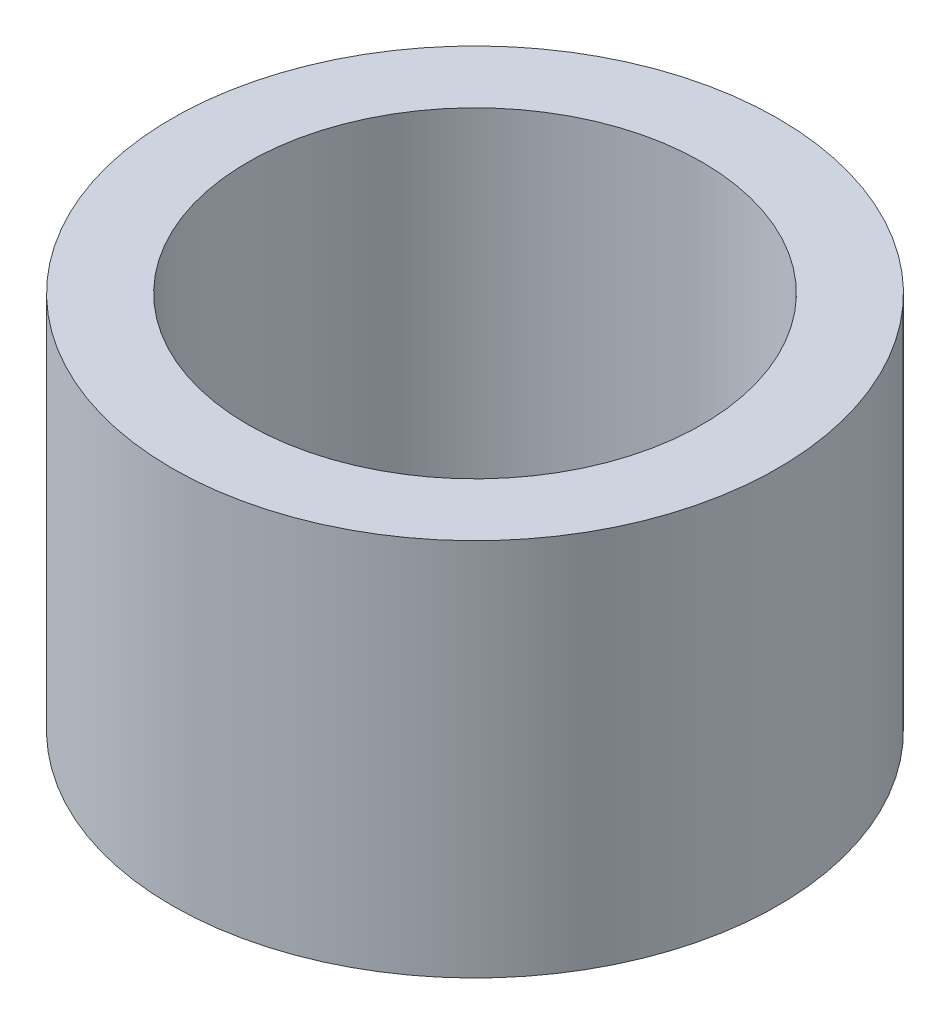
from build123d import *

# Parameters (mm, degrees)
SKETCH1_R           = 4
SKETCH1_R_2         = 3
BOSS_EXTRUDE1_DEPTH = 5


with BuildPart() as part:
    # Sketch1 → Boss-Extrude1 (new body)
    with BuildSketch(Plane(origin=(0, 0, 0), x_dir=(1, 0, 0), z_dir=(0, 1, 0))):
        Circle(SKETCH1_R)
        Circle(SKETCH1_R_2, mode=Mode.SUBTRACT)
    extrude(amount=BOSS_EXTRUDE1_DEPTH)


solid = part.part
